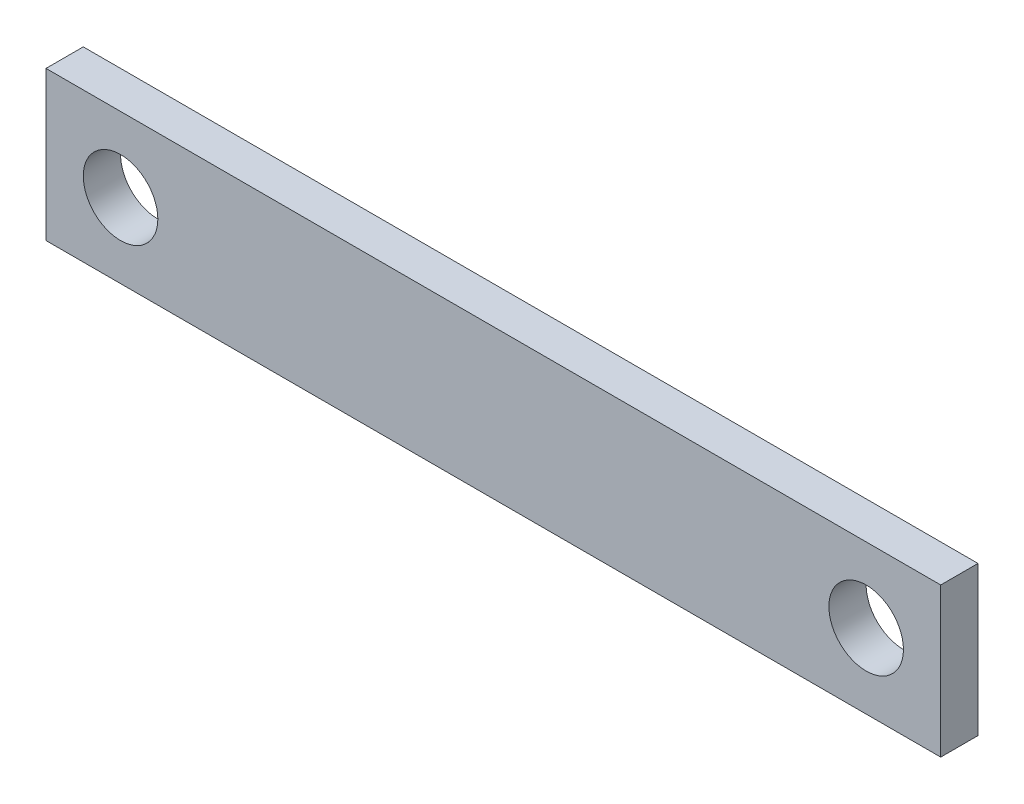
from build123d import *

# Parameters (mm, degrees)
SKETCH1_W           = 76.2
SKETCH1_H           = 12.7
SKETCH1_R           = 3.175
BOSS_EXTRUDE1_DEPTH = 3.175


with BuildPart() as part:
    # Sketch1 → Boss-Extrude1 (new body)
    with BuildSketch(Plane.XY):
        with Locations((38.1, 6.35)):
            Rectangle(SKETCH1_W, SKETCH1_H)
        with Locations((6.35, 6.35)):
            Circle(SKETCH1_R, mode=Mode.SUBTRACT)
        with Locations((69.85, 6.35)):
            Circle(SKETCH1_R, mode=Mode.SUBTRACT)
    extrude(amount=BOSS_EXTRUDE1_DEPTH)


solid = part.part
